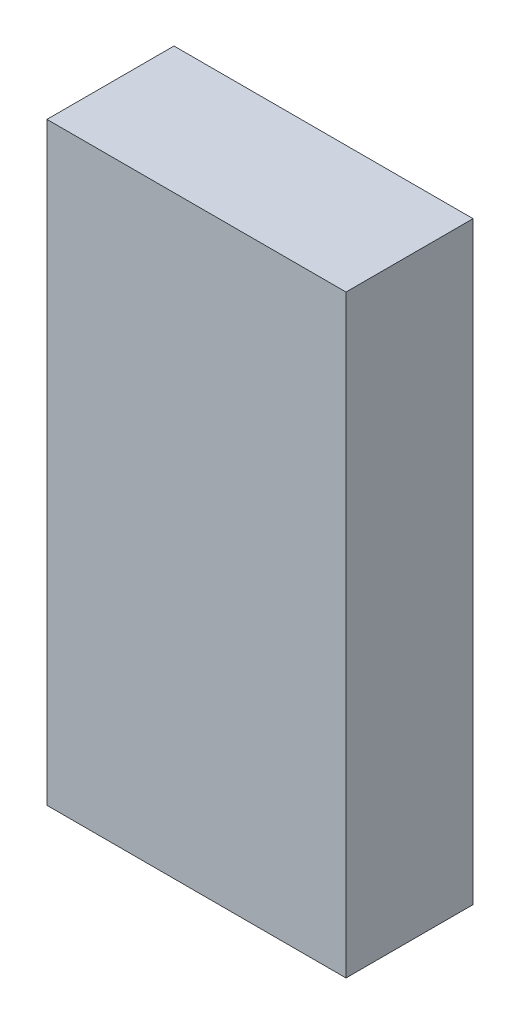
from build123d import *

# Parameters (mm, degrees)
SKETCH1_W           = 24.511
SKETCH1_H           = 10.414
BOSS_EXTRUDE1_DEPTH = 48.6918


with BuildPart() as part:
    # Sketch1 → Boss-Extrude1 (new body)
    with BuildSketch(Plane(origin=(0, 0, 0), x_dir=(1, 0, 0), z_dir=(0, 1, 0))):
        Rectangle(SKETCH1_W, SKETCH1_H)
    extrude(amount=BOSS_EXTRUDE1_DEPTH)


solid = part.part
